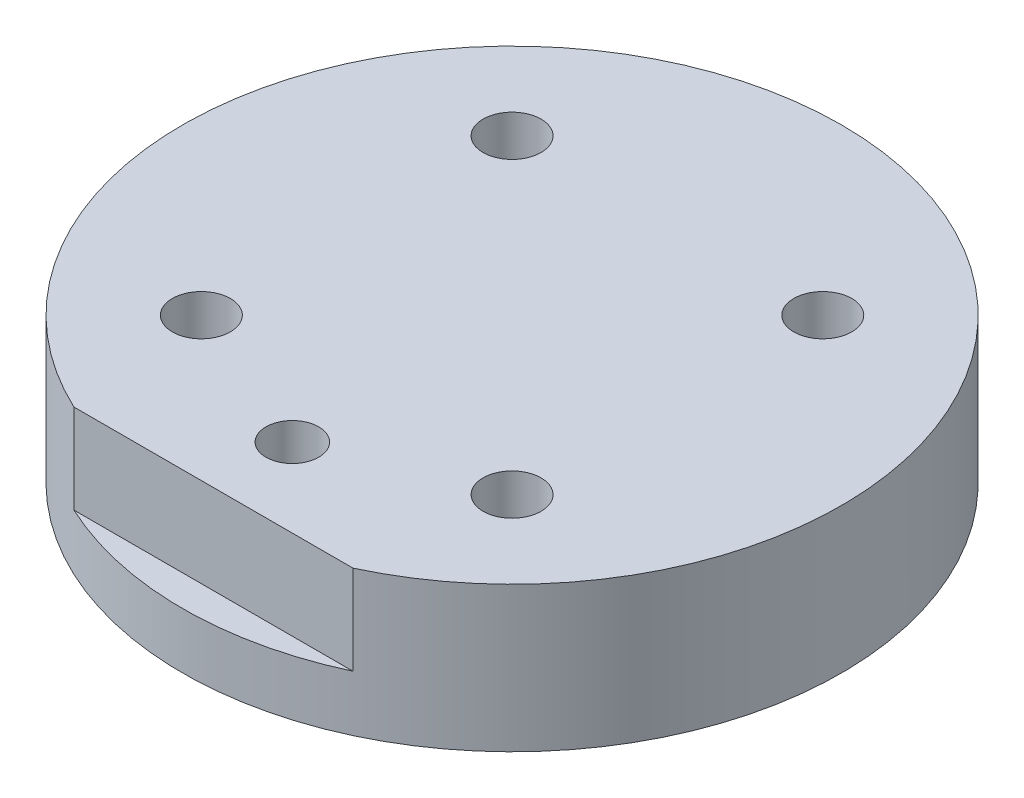
from build123d import *

# Parameters (mm, degrees)
SKETCH2_R                                       = 37.5
BOSS_EXTRUDE1_DEPTH                             = 13.97
CSK_FOR_M6_FLAT_HEAD_MACHINE_SCREW1_D           = 6.6
CSK_FOR_M6_FLAT_HEAD_MACHINE_SCREW1_CSINK_D     = 12.6
CSK_FOR_M6_FLAT_HEAD_MACHINE_SCREW1_CSINK_ANGLE = 90
M5X0_8_TAPPED_HOLE1_D                           = 4.2
M5X0_8_TAPPED_HOLE1_DEPTH                       = 12.192
M5X0_8_TAPPED_HOLE1_TIP                         = 1.2618073
SKETCH1_R                                       = 1.9685
CUT_EXTRUDE1_DEPTH                              = 5.08
SKETCH1_3_W                                     = 12.7
SKETCH1_3_H                                     = 6.35
POGO_PINS_DEPTH                                 = 3.048
CUT_EXTRUDE2_START                              = -10.16
SKETCH8_R                                       = 3
CUT_EXTRUDE2_DEPTH                              = 10.16
LIP_START                                       = 2.54
SKETCH9_R                                       = 37.5
SKETCH9_R_2                                     = 34.96
LIP_DEPTH                                       = 2.54
CHAMFER1_SIZE                                   = 0.508


with BuildPart() as part:
    # Sketch2 → Boss-Extrude1 (new body)
    with BuildSketch(Plane(origin=(0, 0, 0), x_dir=(1, 0, 0), z_dir=(0, 1, 0))):
        Circle(SKETCH2_R)
    extrude(amount=BOSS_EXTRUDE1_DEPTH)

    # CSK for M6 Flat Head Machine Screw1 (through all)
    with Locations(Plane(origin=(0, 0, 0), x_dir=(-1, 0, 0), z_dir=(0, -1, 0))):
        with Locations((-17.67766953, 17.67766953), (17.67766953, 17.67766953), (17.67766953, -17.67766953), (-17.67766953, -17.67766953)):
            CounterSinkHole(CSK_FOR_M6_FLAT_HEAD_MACHINE_SCREW1_D / 2, CSK_FOR_M6_FLAT_HEAD_MACHINE_SCREW1_CSINK_D / 2, counter_sink_angle=CSK_FOR_M6_FLAT_HEAD_MACHINE_SCREW1_CSINK_ANGLE)

    # M5x0.8 Tapped Hole1
    with Locations(Plane(origin=(0, 0, 0), x_dir=(-1, 0, 0), z_dir=(0, -1, 0))):
        with Locations((-27.305, 16.1925), (-27.305, -16.1925), (27.305, -16.1925), (27.305, 16.1925)):
            Hole(M5X0_8_TAPPED_HOLE1_D / 2, depth=M5X0_8_TAPPED_HOLE1_DEPTH)
            with Locations((0, 0, -(M5X0_8_TAPPED_HOLE1_DEPTH + M5X0_8_TAPPED_HOLE1_TIP / 2))):  # 118° drill point
                Cone(0, M5X0_8_TAPPED_HOLE1_D / 2, M5X0_8_TAPPED_HOLE1_TIP, mode=Mode.SUBTRACT)

    # Sketch1 → Cut-Extrude1 (cut)
    with BuildSketch(Plane(origin=(0, 0, 0), x_dir=(1, 0, 0), z_dir=(0, 1, 0))):
        with Locations((-30.515, 0)):
            Circle(SKETCH1_R)
    extrude(amount=CUT_EXTRUDE1_DEPTH, mode=Mode.SUBTRACT)

    # Sketch1_3 → Pogo pins (add)
    with BuildSketch(Plane(origin=(0, 0, 0), x_dir=(1, 0, 0), z_dir=(0, 1, 0))):
        with Locations((-12.5572, 0)):
            Rectangle(SKETCH1_3_W, SKETCH1_3_H)
    extrude(amount=-POGO_PINS_DEPTH)

    # Sketch8 → Cut-Extrude2 (cut)
    with BuildSketch(Plane(origin=(0, 13.97, 0), x_dir=(1, 0, 0), z_dir=(0, 1, 0)).offset(CUT_EXTRUDE2_START)):
        with BuildLine():
            ThreePointArc((-15.875, -33.974025004), (0, -37.5), (15.875, -33.974025004))
            Line((15.875, -33.974025004), (-15.875, -33.974025004))
        make_face()
        with Locations((0, -25)):
            Circle(SKETCH8_R)
    extrude(amount=CUT_EXTRUDE2_DEPTH, mode=Mode.SUBTRACT)

    # Sketch9 → Lip (add)
    with BuildSketch(Plane.XZ.offset(LIP_START)):
        Circle(SKETCH9_R)
        Circle(SKETCH9_R_2, mode=Mode.SUBTRACT)
    extrude(amount=-LIP_DEPTH)

    # Chamfer1
    chamfer1_edges = [part.edges().sort_by_distance(p)[0] for p in [
        (-34.96, -2.54, 0),
    ]]
    chamfer(chamfer1_edges, length=CHAMFER1_SIZE)


solid = part.part
